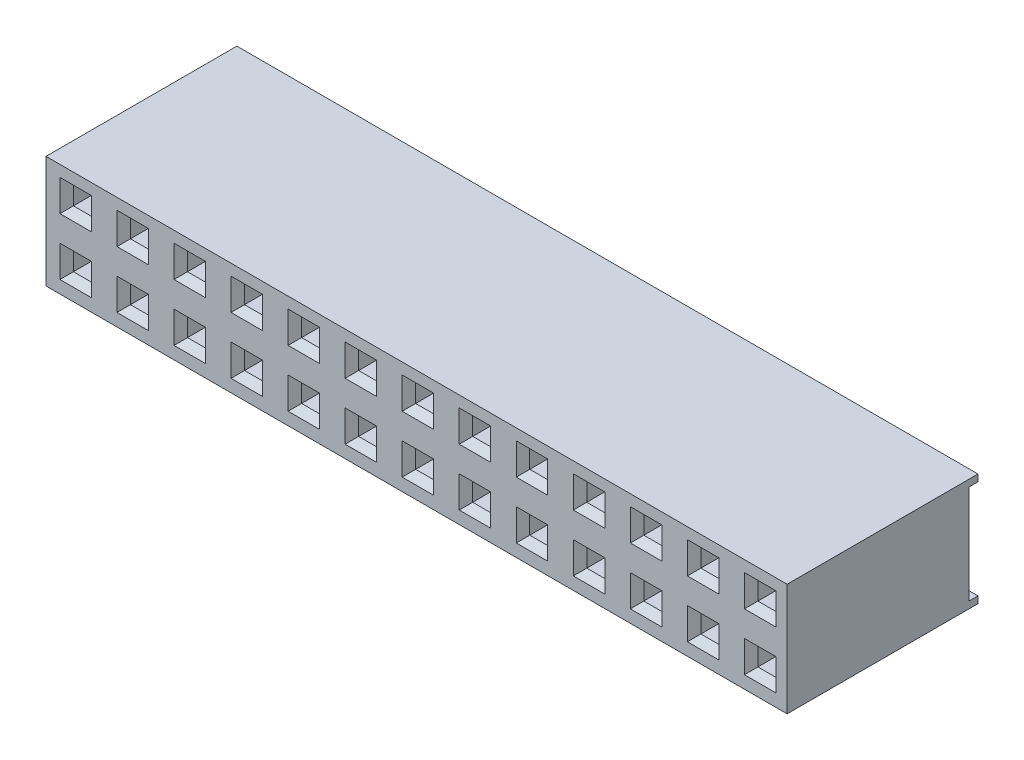
from build123d import *

# Parameters (mm, degrees)
BOSS_EXTRUDE1_DEPTH  = 33
SKETCH2_W            = 1.6
SKETCH2_H            = 0.6
CUT_EXTRUDE1_DEPTH   = 2
SKETCH3_W            = 0.8
SKETCH3_H            = 0.8
CUT_EXTRUDE2_DEPTH   = 2.5
SKETCH4_W            = 1.4
SKETCH4_H            = 1.4
CUT_EXTRUDE3_DEPTH   = 0.5
CUT_EXTRUDE3_TAPER   = 45
LPATTERN1_COUNT      = 17
LPATTERN1_PITCH      = 2.54
LPATTERN1_COUNT_DIR2 = 3
LPATTERN1_PITCH_DIR2 = 2.54


with BuildPart() as part:
    # Sketch1 → Boss-Extrude1 (new body)
    with BuildSketch(Plane(origin=(0, 0, 0), x_dir=(0, 0, -1), z_dir=(1, 0, 0))):
        Polygon((8.5, 5), (0, 5), (0, 0), (8.5, 0), (8.5, 0.3), (8.1, 0.3), (8.1, 4.7), (8.5, 4.7), align=None)
    extrude(amount=-BOSS_EXTRUDE1_DEPTH)

    # Sketch2 → Cut-Extrude1 (cut)
    with BuildSketch(Plane(origin=(0, 0, -8.1), x_dir=(-1, 0, 0), z_dir=(0, 0, -1))):
        with Locations((1.2, 3.9)):
            Rectangle(SKETCH2_W, SKETCH2_H)
    cut_extrude1 = extrude(amount=-CUT_EXTRUDE1_DEPTH, mode=Mode.SUBTRACT)

    # Sketch3 → Cut-Extrude2 (cut)
    with BuildSketch(Plane(origin=(0, 0, 0), x_dir=(-1, 0, 0), z_dir=(0, 0, -1))):
        with Locations((1.2, 3.8)):
            Rectangle(SKETCH3_W, SKETCH3_H)
    cut_extrude2 = extrude(amount=CUT_EXTRUDE2_DEPTH, mode=Mode.SUBTRACT)

    # Sketch4 → Cut-Extrude3 (cut)
    with BuildSketch(Plane.XY):
        with Locations((-1.2, 3.8)):
            Rectangle(SKETCH4_W, SKETCH4_H)
    cut_extrude3 = extrude(amount=-CUT_EXTRUDE3_DEPTH, taper=CUT_EXTRUDE3_TAPER, mode=Mode.SUBTRACT)

    # LPattern1: Cut-Extrude1, Cut-Extrude2, Cut-Extrude3 17 × 3
    with Locations(*[(-i * LPATTERN1_PITCH, -j * LPATTERN1_PITCH_DIR2, 0) for i in range(LPATTERN1_COUNT) for j in range(LPATTERN1_COUNT_DIR2) if (i, j) != (0, 0)]):
        add(cut_extrude1, mode=Mode.SUBTRACT)
        add(cut_extrude2, mode=Mode.SUBTRACT)
        add(cut_extrude3, mode=Mode.SUBTRACT)


solid = part.part
